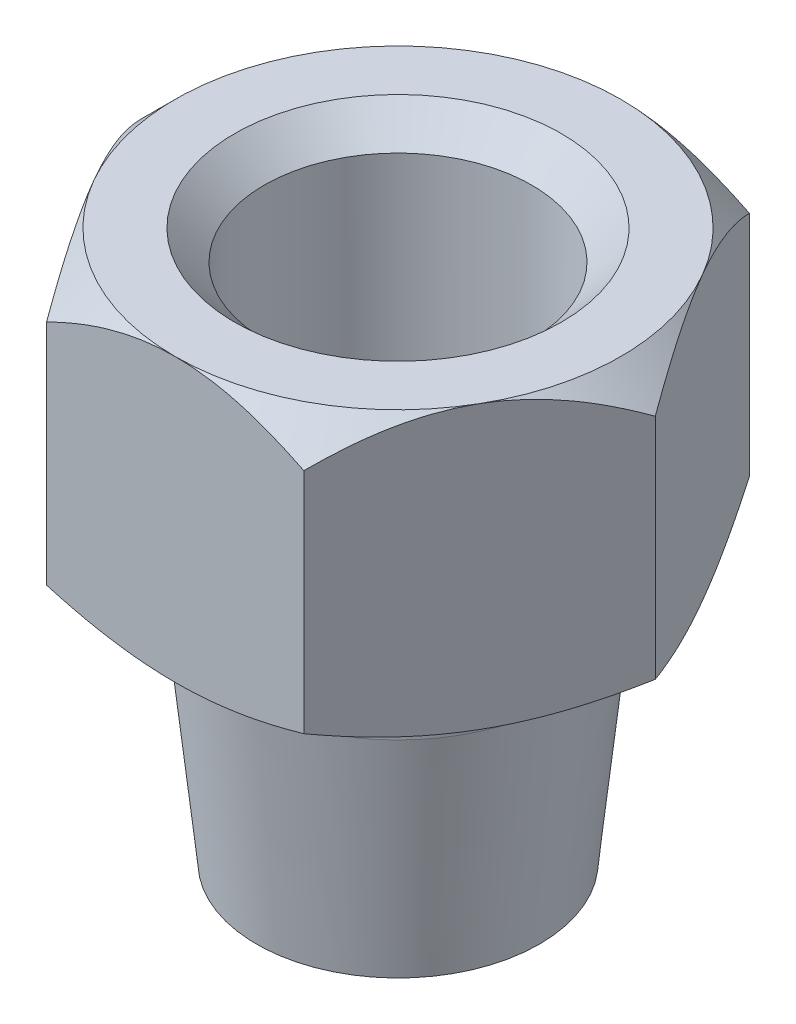
from build123d import *

# Parameters (mm, degrees)
CROQUIS4_OUTSIDE_W    = 60.478
CROQUIS4_OUTSIDE_H    = 60.478
CORTAR_EXTRUIR6_DEPTH = 70
CROQUIS5_OUTSIDE_W    = 188.422
CROQUIS5_OUTSIDE_H    = 183.78
CROQUIS5_OUTSIDE_R    = 15
CORTAR_EXTRUIR7_DEPTH = 70
CORTAR_EXTRUIR7_TAPER = 45
CROQUIS6_R            = 9
CORTAR_EXTRUIR8_DEPTH = 15
CHAFL_N1_SIZE         = 2
REDONDEO1_R           = 1
CROQUIS7_OUTSIDE_W    = 83.062
CROQUIS7_OUTSIDE_H    = 78.42
CROQUIS7_OUTSIDE_R    = 15
CORTAR_EXTRUIR9_DEPTH = 10
CORTAR_EXTRUIR9_TAPER = 60


with BuildPart() as part:
    # Croquis1 → Revolución1 (revolve)
    with BuildSketch(Plane.XY):
        Polygon((6.35, 31.379194031), (20, 31.379194031), (22, 31.379194031), (22, 29.379194031), (22, 14.379194031), (22, 12.379194031), (20, 12.379194031), (14, 12.379194031), (11.11, 12.379194031), (11.11, 9.379194031), (9.525, -5.620805969), (1.5875, -5.620805969), (1.5875, 12.379194031), (6.35, 12.379194031), align=None)
    revolve(axis=Axis((0, 51.930492424, 0), (0, -1, 0)))

    # Croquis4 outside → Cortar-Extruir6 (cut)
    with BuildSketch(Plane(origin=(0, 31.379194031, 0), x_dir=(1, 0, 0), z_dir=(0, 1, 0))):
        Rectangle(CROQUIS4_OUTSIDE_W, CROQUIS4_OUTSIDE_H)
        Polygon((17.320508076, 0), (8.660254038, 15), (-8.660254038, 15), (-17.320508076, 0), (-8.660254038, -15), (8.660254038, -15), align=None, mode=Mode.SUBTRACT)
    extrude(amount=-CORTAR_EXTRUIR6_DEPTH, mode=Mode.SUBTRACT)

    # Croquis5 outside → Cortar-Extruir7 (cut)
    with BuildSketch(Plane(origin=(0, 31.379194031, 0), x_dir=(1, 0, 0), z_dir=(0, 1, 0))):
        Rectangle(CROQUIS5_OUTSIDE_W, CROQUIS5_OUTSIDE_H)
        Circle(CROQUIS5_OUTSIDE_R, mode=Mode.SUBTRACT)
    extrude(amount=-CORTAR_EXTRUIR7_DEPTH, taper=CORTAR_EXTRUIR7_TAPER, mode=Mode.SUBTRACT)

    # Croquis6 → Cortar-Extruir8 (cut)
    with BuildSketch(Plane(origin=(0, 31.379194031, 0), x_dir=(1, 0, 0), z_dir=(0, 1, 0))):
        Circle(CROQUIS6_R)
    extrude(amount=-CORTAR_EXTRUIR8_DEPTH, mode=Mode.SUBTRACT)

    # Chaflán1
    chafl_n1_edges = [part.edges().sort_by_distance(p)[0] for p in [
        (-9, 31.379194031, 0),
    ]]
    chamfer(chafl_n1_edges, length=CHAFL_N1_SIZE)

    # Redondeo1
    redondeo1_edges = [part.edges().sort_by_distance(p)[0] for p in [
        (-6.35, 16.379194031, 0),
    ]]
    fillet(redondeo1_edges, radius=REDONDEO1_R)

    # Croquis7 outside → Cortar-Extruir9 (cut)
    with BuildSketch(Plane.XZ.offset(-12.379194031)):
        Rectangle(CROQUIS7_OUTSIDE_W, CROQUIS7_OUTSIDE_H)
        Circle(CROQUIS7_OUTSIDE_R, mode=Mode.SUBTRACT)
    extrude(amount=-CORTAR_EXTRUIR9_DEPTH, taper=CORTAR_EXTRUIR9_TAPER, mode=Mode.SUBTRACT)


solid = part.part
